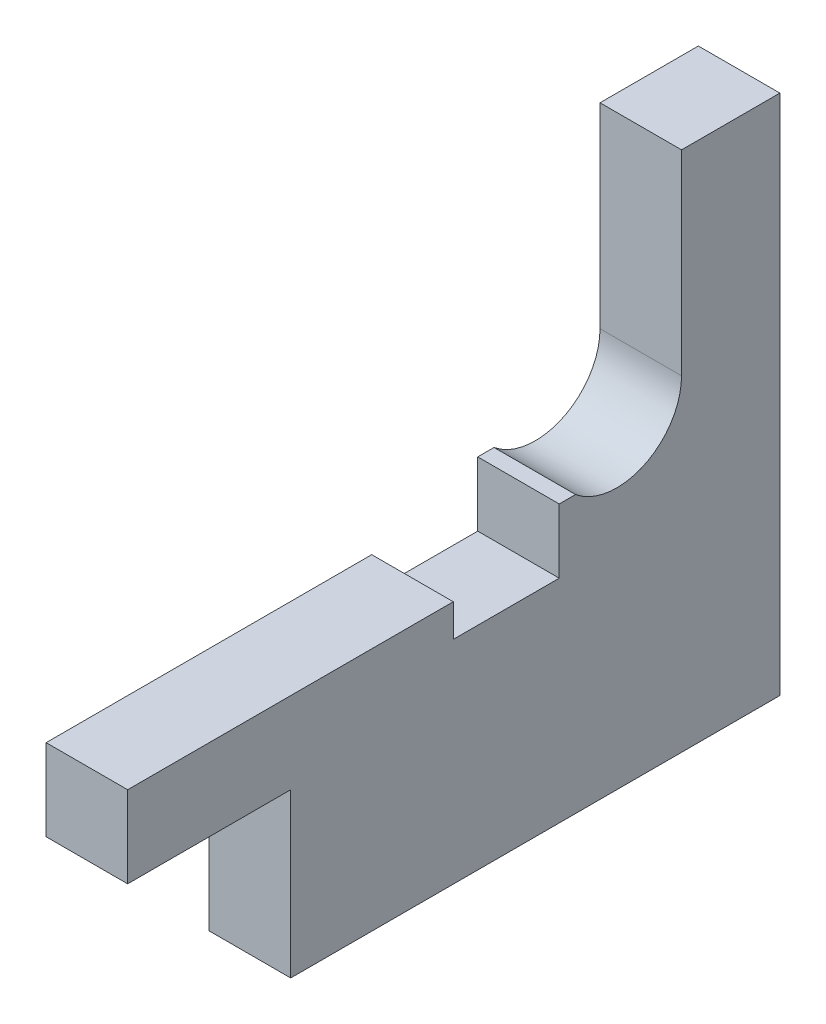
from build123d import *

# Parameters (mm, degrees)
BOSS_EXTRUDE1_DEPTH = 5


with BuildPart() as part:
    # Sketch1 → Boss-Extrude1 (new body)
    with BuildSketch(Plane(origin=(0, 0, 0), x_dir=(0, 0, -1), z_dir=(1, 0, 0))):
        with BuildLine():
            Line((3.96875, 0), (3.96875, 12))
            Line((3.96875, 12), (10, 12))
            Line((10, 12), (10, -20))
            Line((10, -20), (-20, -20))
            Line((-20, -20), (-20, -10))
            Line((-20, -10), (-30, -10))
            Line((-30, -10), (-30, -5))
            Line((-30, -5), (-10.03125, -5))
            Line((-10.03125, -5), (-10.03125, -7))
            Line((-10.03125, -7), (-3.53125, -7))
            Line((-3.53125, -7), (-3.53125, -3.056754815))
            Line((-3.53125, -3.056754815), (-2.53125, -3.056754815))
            ThreePointArc((-2.53125, -3.056754815), (1.68894614, -3.591439475), (3.96875, 0))
        make_face()
    extrude(amount=BOSS_EXTRUDE1_DEPTH)


solid = part.part
